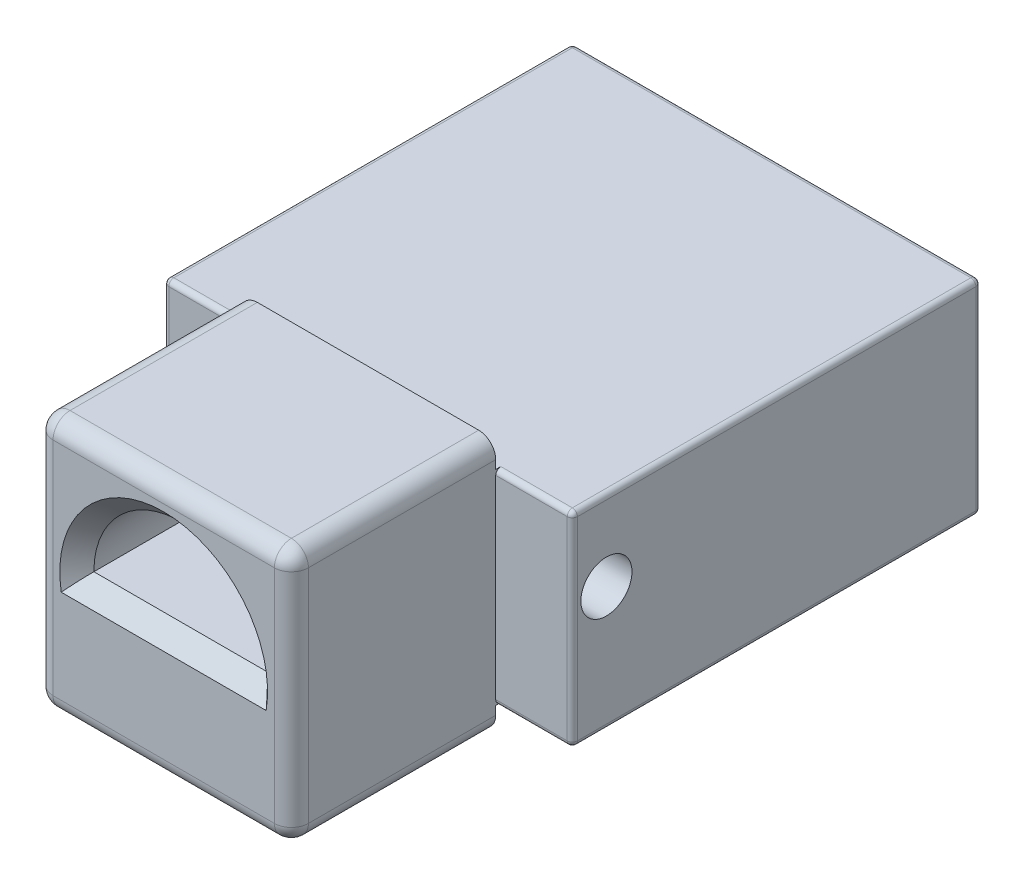
from build123d import *

# Parameters (mm, degrees)
SKIZZE1_W                          = 15
SKIZZE1_H                          = 15
AUFSATZ_LINEAR_AUSTRAGEN1_DEPTH    = 10
FASE1_SIZE                         = 1
SKIZZE1_2_W                        = 15
SKIZZE1_2_H                        = 15
AUFSATZ_LINEAR_AUSTRAGEN2_DEPTH    = 2
VERRUNDUNG1_R                      = 1
SKIZZE2_W                          = 24
SKIZZE2_H                          = 12
AUFSATZ_LINEAR_AUSTRAGEN3_DEPTH    = 24
F_1_0_1_DURCHMESSER_BOHRUNG1_D     = 1
F_1_0_1_DURCHMESSER_BOHRUNG1_DEPTH = 12
F_1_0_1_DURCHMESSER_BOHRUNG1_TIP   = 0.30043031
F_1_0_1_DURCHMESSER_BOHRUNG2_D     = 1
F_1_0_1_DURCHMESSER_BOHRUNG2_DEPTH = 2.2
F_1_0_1_DURCHMESSER_BOHRUNG2_TIP   = 0.30043031
F_3_0_3_DURCHMESSER_BOHRUNG1_D     = 3
F_3_0_3_DURCHMESSER_BOHRUNG1_DEPTH = 9
F_3_0_3_DURCHMESSER_BOHRUNG1_TIP   = 0.901290929
F_2_0_2_DURCHMESSER_BOHRUNG1_D     = 2
F_2_0_2_DURCHMESSER_BOHRUNG1_DEPTH = 1
F_2_0_2_DURCHMESSER_BOHRUNG1_TIP   = 0.600860619
VERRUNDUNG6_R                      = 0.3


with BuildPart() as part:
    # Skizze1 → Aufsatz-Linear austragen1 (new body)
    with BuildSketch(Plane.XY):
        Rectangle(SKIZZE1_W, SKIZZE1_H)
        with BuildLine():
            Line((-5.1, 0), (5.1, 0))
            ThreePointArc((5.1, 0), (0, 5.1), (-5.1, 0))
        make_face(mode=Mode.SUBTRACT)
    extrude(amount=AUFSATZ_LINEAR_AUSTRAGEN1_DEPTH)

    # Fase1
    fase1_edges = [part.edges().sort_by_distance(p)[0] for p in [
        (0, 5.1, 10),
        (0, 0, 10),
    ]]
    chamfer(fase1_edges, length=FASE1_SIZE)

    # Skizze1_2 → Aufsatz-Linear austragen2 (add)
    with BuildSketch(Plane.XY):
        Rectangle(SKIZZE1_2_W, SKIZZE1_2_H)
        with BuildLine():
            ThreePointArc((5.1, 0), (0, 5.1), (-5.1, 0))
            Line((-5.1, 0), (5.1, 0))
        make_face(mode=Mode.SUBTRACT)
        with BuildLine():
            Line((-5.1, 0), (5.1, 0))
            ThreePointArc((5.1, 0), (0, 5.1), (-5.1, 0))
        make_face()
    extrude(amount=-AUFSATZ_LINEAR_AUSTRAGEN2_DEPTH)

    # Verrundung1
    verrundung1_edges = [part.edges().sort_by_distance(p)[0] for p in [
        (-7.5, 0, 10),
        (0, -7.5, 10),
        (7.5, 0, 10),
        (0, 7.5, 10),
        (7.5, -7.5, 4),
        (-7.5, -7.5, 4),
        (-7.5, 7.5, 4),
        (7.5, 7.5, 4),
    ]]
    fillet(verrundung1_edges, radius=VERRUNDUNG1_R)

    # Skizze2 → Aufsatz-Linear austragen3 (add)
    with BuildSketch(Plane(origin=(0, 0, -2), x_dir=(-1, 0, 0), z_dir=(0, 0, -1))):
        Rectangle(SKIZZE2_W, SKIZZE2_H)
    extrude(amount=AUFSATZ_LINEAR_AUSTRAGEN3_DEPTH)

    # Skizze12 → Schnitt-Rotation1 (revolve, cut)
    with BuildSketch(Plane(origin=(0, 0, 0), x_dir=(1, 0, 0), z_dir=(0, 1, 0)), mode=Mode.PRIVATE) as schnitt_rotation1_sk:
        Polygon((-1, 2), (-4.879193576, 24), (0, 24), (0, 2), align=None)
    revolve(schnitt_rotation1_sk.sketch.rotate(Axis((0, 0, -2), (0, 0, -1)), 180), axis=Axis((0, 0, -2), (0, 0, -1)), mode=Mode.SUBTRACT)  # turned: the seam where the file's is

    # 1.0 _1_ Durchmesser Bohrung1
    with Locations(Plane(origin=(12, 0, -12), x_dir=(0, 0, 1), z_dir=(1, 0, 0))):
        with Locations((8, -1.3)):
            Hole(F_1_0_1_DURCHMESSER_BOHRUNG1_D / 2, depth=F_1_0_1_DURCHMESSER_BOHRUNG1_DEPTH)
            with Locations((0, 0, -(F_1_0_1_DURCHMESSER_BOHRUNG1_DEPTH + F_1_0_1_DURCHMESSER_BOHRUNG1_TIP / 2))):  # 118° drill point
                Cone(0, F_1_0_1_DURCHMESSER_BOHRUNG1_D / 2, F_1_0_1_DURCHMESSER_BOHRUNG1_TIP, mode=Mode.SUBTRACT)

    # 1.0 _1_ Durchmesser Bohrung2
    with Locations(Plane(origin=(0, 0, -26), x_dir=(-1, 0, 0), z_dir=(0, 0, -1))):
        with Locations((0, 4.170639233)):
            Hole(F_1_0_1_DURCHMESSER_BOHRUNG2_D / 2, depth=F_1_0_1_DURCHMESSER_BOHRUNG2_DEPTH)
            with Locations((0, 0, -(F_1_0_1_DURCHMESSER_BOHRUNG2_DEPTH + F_1_0_1_DURCHMESSER_BOHRUNG2_TIP / 2))):  # 118° drill point
                Cone(0, F_1_0_1_DURCHMESSER_BOHRUNG2_D / 2, F_1_0_1_DURCHMESSER_BOHRUNG2_TIP, mode=Mode.SUBTRACT)

    # 3.0 _3_ Durchmesser Bohrung1
    with Locations(Plane(origin=(12, 0, -12), x_dir=(0, 0, 1), z_dir=(1, 0, 0))):
        with Locations((8, -1.3)):
            Hole(F_3_0_3_DURCHMESSER_BOHRUNG1_D / 2, depth=F_3_0_3_DURCHMESSER_BOHRUNG1_DEPTH)
            with Locations((0, 0, -(F_3_0_3_DURCHMESSER_BOHRUNG1_DEPTH + F_3_0_3_DURCHMESSER_BOHRUNG1_TIP / 2))):  # 118° drill point
                Cone(0, F_3_0_3_DURCHMESSER_BOHRUNG1_D / 2, F_3_0_3_DURCHMESSER_BOHRUNG1_TIP, mode=Mode.SUBTRACT)

    # 2.0 _2_ Durchmesser Bohrung1
    with Locations(Plane(origin=(0, 0, -26), x_dir=(-1, 0, 0), z_dir=(0, 0, -1))):
        with Locations((0, 4.170639233)):
            Hole(F_2_0_2_DURCHMESSER_BOHRUNG1_D / 2, depth=F_2_0_2_DURCHMESSER_BOHRUNG1_DEPTH)
            with Locations((0, 0, -(F_2_0_2_DURCHMESSER_BOHRUNG1_DEPTH + F_2_0_2_DURCHMESSER_BOHRUNG1_TIP / 2))):  # 118° drill point
                Cone(0, F_2_0_2_DURCHMESSER_BOHRUNG1_D / 2, F_2_0_2_DURCHMESSER_BOHRUNG1_TIP, mode=Mode.SUBTRACT)

    # Verrundung6
    verrundung6_edges = [part.edges().sort_by_distance(p)[0] for p in [
        (-12, 0, -2),
        (-12, -6, -14),
        (-9.75, 6, -2),
        (9.75, 6, -2),
        (-12, 6, -14),
        (12, 0, -2),
        (12, 6, -14),
        (9.75, -6, -2),
        (-9.75, -6, -2),
        (12, -6, -14),
        (-12, 0, -26),
        (0, 6, -26),
        (12, 0, -26),
        (0, -6, -26),
    ]]
    fillet(verrundung6_edges, radius=VERRUNDUNG6_R)


solid = part.part
